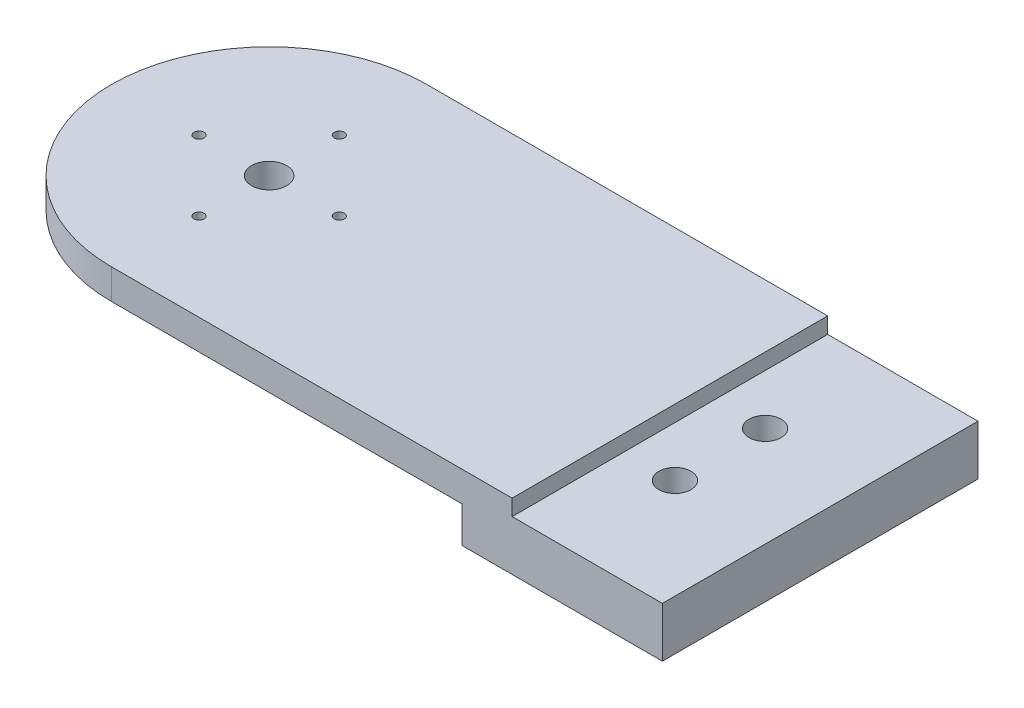
from build123d import *

# Parameters (mm, degrees)
EXTRUDE_1_DEPTH     = 3
SKETCH_3_W          = 20
SKETCH_3_H          = 31.5
EXTRUDE_2_DEPTH     = 2
SKETCH_4_R          = 0.5
CUT_EXTRUDE_1_DEPTH = 10
SKETCH_5_R          = 1.6
CUT_EXTRUDE_2_DEPTH = 10
SKETCH_6_R          = 1.75
CUT_EXTRUDE_3_DEPTH = 17
CUT_EXTRUDE_4_DEPTH = 1.6
EXTRUDE_3_DEPTH     = 3
SKETCH_9_W          = 31.5
SKETCH_9_H          = 1.6
EXTRUDE_4_DEPTH     = 3
SKETCH_10_R         = 1.75
SKETCH_10_R_2       = 0.5
CUT_EXTRUDE_5_DEPTH = 10
SKETCH_12_R         = 10
EXTRUDE_6_DEPTH     = 1.6
SKETCH_13_W         = 31.5
SKETCH_13_H         = 1.6
EXTRUDE_7_DEPTH     = 2
SKETCH_15_R         = 1.75
SKETCH_15_R_2       = 0.5
CUT_EXTRUDE_6_DEPTH = 12


with BuildPart() as part:
    # 草图1 → 凸台-拉伸1 (new body)
    with BuildSketch(Plane(origin=(0, 0, 0), x_dir=(1, 0, 0), z_dir=(0, 1, 0))):
        with BuildLine():
            Line((0, -15.75), (55, -15.75))
            Line((55, -15.75), (55, 15.75))
            Line((55, 15.75), (0, 15.75))
            ThreePointArc((0, 15.75), (-15.75, 0), (0, -15.75))
        make_face()
    extrude(amount=EXTRUDE_1_DEPTH)

    # 草图3 → 凸台-拉伸2 (add)
    with BuildSketch(Plane.XZ):
        with Locations((45, 0)):
            Rectangle(SKETCH_3_W, SKETCH_3_H)
    extrude(amount=EXTRUDE_2_DEPTH)

    # 草图4 → 切除-拉伸1 (cut)
    with BuildSketch(Plane.XZ):
        with Locations((0, 7)):
            Circle(SKETCH_4_R)
        with Locations((7, 0)):
            Circle(SKETCH_4_R)
        with Locations((0, -7)):
            Circle(SKETCH_4_R)
        with Locations((-7, 0)):
            Circle(SKETCH_4_R)
    extrude(amount=-CUT_EXTRUDE_1_DEPTH, mode=Mode.SUBTRACT)

    # 草图5 → 切除-拉伸2 (cut)
    with BuildSketch(Plane.XZ.offset(2)):
        with Locations((45, -4.5)):
            Circle(SKETCH_5_R)
        with Locations((45, 4.5)):
            Circle(SKETCH_5_R)
    extrude(amount=-CUT_EXTRUDE_2_DEPTH, mode=Mode.SUBTRACT)

    # 草图6 → 切除-拉伸3 (cut)
    with BuildSketch(Plane.XZ):
        Circle(SKETCH_6_R)
    extrude(amount=-CUT_EXTRUDE_3_DEPTH, mode=Mode.SUBTRACT)

    # 草图7 → 切除-拉伸4 (cut)
    with BuildSketch(Plane.XZ):
        with BuildLine():
            Line((35, -15.75), (35, 15.75))
            Line((35, 15.75), (0, 15.75))
            ThreePointArc((0, 15.75), (-15.75, 0), (0, -15.75))
            Line((0, -15.75), (35, -15.75))
        make_face()
    extrude(amount=-CUT_EXTRUDE_4_DEPTH, mode=Mode.SUBTRACT)

    # 草图8 → 凸台-拉伸3 (add)
    with BuildSketch(Plane.XZ.offset(-1.6)):
        with BuildLine():
            Line((0, -15.75), (35, -15.75))
            Line((35, -15.75), (35, 15.75))
            Line((35, 15.75), (0, 15.75))
            ThreePointArc((0, 15.75), (-15.75, 0), (0, -15.75))
        make_face()
    extrude(amount=-EXTRUDE_3_DEPTH)

    # 草图9 → 凸台-拉伸4 (add)
    with BuildSketch(Plane(origin=(35, 0, 0), x_dir=(0, 0, -1), z_dir=(1, 0, 0))):
        with Locations((0, 3.8)):
            Rectangle(SKETCH_9_W, SKETCH_9_H)
    extrude(amount=EXTRUDE_4_DEPTH)

    # 草图10 → 切除-拉伸5 (cut)
    with BuildSketch(Plane.XZ.offset(-1.6)):
        Circle(SKETCH_10_R)
        with Locations((0, 7)):
            Circle(SKETCH_10_R_2)
        with Locations((7, 0)):
            Circle(SKETCH_10_R_2)
        with Locations((0, -7)):
            Circle(SKETCH_10_R_2)
        with Locations((-7, 0)):
            Circle(SKETCH_10_R_2)
    extrude(amount=-CUT_EXTRUDE_5_DEPTH, mode=Mode.SUBTRACT)

    # 草图12 → 凸台-拉伸6 (add)
    with BuildSketch(Plane.XZ.offset(-1.6)):
        Circle(SKETCH_12_R)
    extrude(amount=EXTRUDE_6_DEPTH)

    # 草图13 → 凸台-拉伸7 (add)
    with BuildSketch(Plane(origin=(38, 0, 0), x_dir=(0, 0, -1), z_dir=(1, 0, 0))):
        with Locations((0, 3.8)):
            Rectangle(SKETCH_13_W, SKETCH_13_H)
    extrude(amount=EXTRUDE_7_DEPTH)

    # 草图15 → 切除-拉伸6 (cut)
    with BuildSketch(Plane.XZ):
        Circle(SKETCH_15_R)
        with Locations((7, 0)):
            Circle(SKETCH_15_R_2)
        with Locations((0, -7)):
            Circle(SKETCH_15_R_2)
        with Locations((0, 7)):
            Circle(SKETCH_15_R_2)
        with Locations((-7, 0)):
            Circle(SKETCH_15_R_2)
    extrude(amount=-CUT_EXTRUDE_6_DEPTH, mode=Mode.SUBTRACT)


solid = part.part
